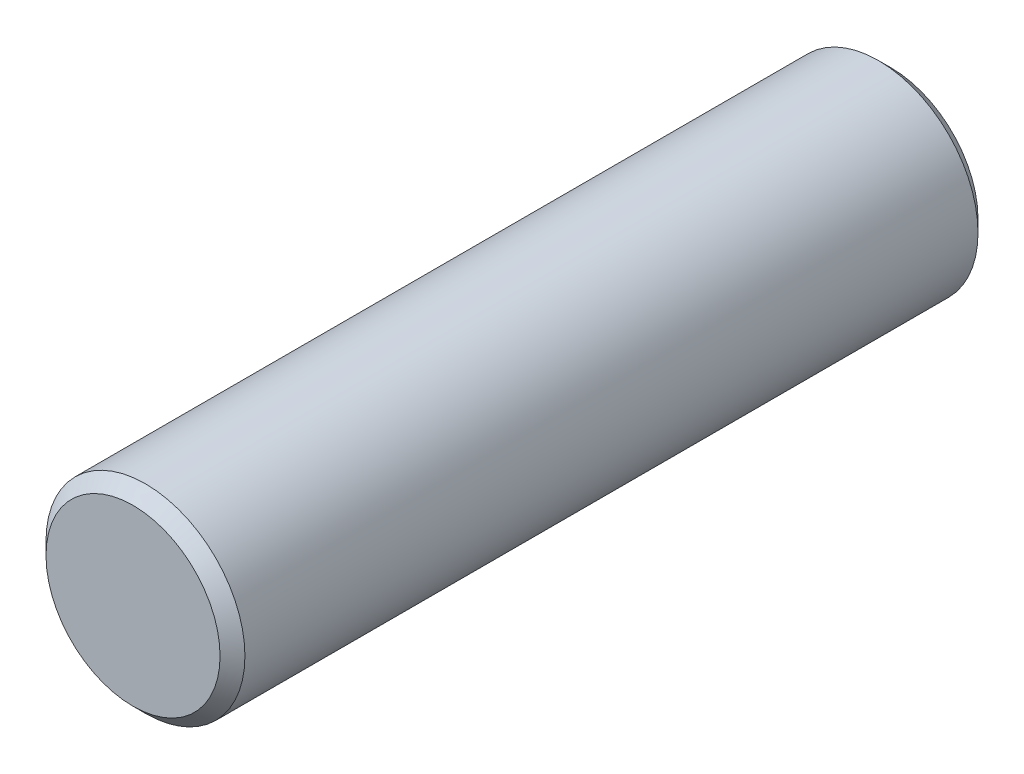
from build123d import *

# Parameters (mm, degrees)
SKETCH1_R           = 4
BOSS_EXTRUDE1_DEPTH = 30.48
CHAMFER1_SIZE       = 0.5


with BuildPart() as part:
    # Sketch1 → Boss-Extrude1 (new body)
    with BuildSketch(Plane.XY):
        Circle(SKETCH1_R)
    extrude(amount=BOSS_EXTRUDE1_DEPTH)

    # Chamfer1
    chamfer1_edges = [part.edges().sort_by_distance(p)[0] for p in [
        (-4, 0, 0),
        (-4, 0, 30.48),
    ]]
    chamfer(chamfer1_edges, length=CHAMFER1_SIZE)


solid = part.part
